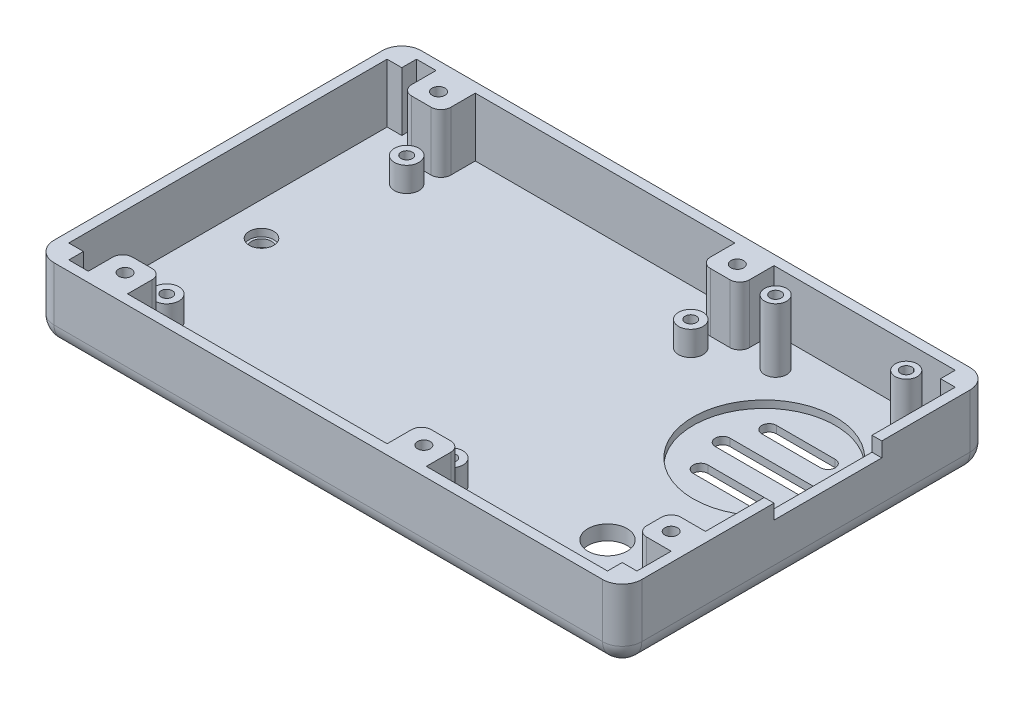
from build123d import *

# Parameters (mm, degrees)
SKETCH1_W                   = 120
SKETCH1_H                   = 75
MAIN_STRUCTURE_DEPTH        = 15
SKETCH2_W                   = 116
SKETCH2_H                   = 71
INSIDE_CUT_DEPTH            = 12
SKETCH3_R                   = 2.5
SKETCH3_R_2                 = 1.15
PI_STANDOFFS_DEPTH          = 5
SKETCH4_R                   = 2
SKETCH4_R_2                 = 0.9
CAMERA_STANDOFFS_DEPTH      = 5
BODY_FILLET_1_R             = 4
BODY_FILLET_2_R             = 4
BODY_FILLET_3_R             = 4
BODY_FILLET_4_R             = 4
SKETCH5_R                   = 2.25
SKETCH5_R_2                 = 1.15
FONA_STANDOFFS_DEPTH        = 13
SKETCH6_W                   = 3
SKETCH6_H                   = 3
CORNER_SUPPORT_DEPTH        = 12
SKETCH8_W                   = 22
SKETCH8_H                   = 3
CHARGER_CUTOUT_DEPTH        = 10
SKETCH9_W                   = 8
SKETCH9_H                   = 7
SKETCH9_W_2                 = 7
MOUNTING_STRUCTURE_DEPTH    = 12
MOUNTING_STRUCTURE_FILLET_R = 2
SKETCH10_R                  = 1.3
CASE_MOUNTING_HOLES_DEPTH   = 15
SKETCH13_R                  = 2.9
CASE_SCREW_HEAD_HOLES_DEPTH = 8.85
SKETCH14_R                  = 14.5
SPEAKER_HOLDER_DEPTH        = 1.5
SOUND_CUTOUT_DEPTH          = 1.5
SKETCH25_R                  = 2.5
MICROPHONE_HOLDER_DEPTH     = 1.5
SKETCH26_R                  = 2
MICROPHONE_CUTOUT_DEPTH     = 1.5
SKETCH27_R                  = 4
CAMERA_CUTOUT_DEPTH         = 10


with BuildPart() as part:
    # Sketch1 → Main Structure (new body)
    with BuildSketch(Plane(origin=(0, 0, 0), x_dir=(1, 0, 0), z_dir=(0, 1, 0))):
        Rectangle(SKETCH1_W, SKETCH1_H)
    extrude(amount=MAIN_STRUCTURE_DEPTH)

    # Sketch2 → Inside Cut (cut)
    with BuildSketch(Plane(origin=(0, 15, 0), x_dir=(1, 0, 0), z_dir=(0, 1, 0))):
        Rectangle(SKETCH2_W, SKETCH2_H)
    extrude(amount=-INSIDE_CUT_DEPTH, mode=Mode.SUBTRACT)

    # Sketch3 → Pi Standoffs (add)
    with BuildSketch(Plane(origin=(0, 3, 0), x_dir=(1, 0, 0), z_dir=(0, 1, 0))):
        with Locations((-46, -24.5)):
            Circle(SKETCH3_R)
        with Locations((-46, -24.5)):
            Circle(SKETCH3_R_2, mode=Mode.SUBTRACT)
        with Locations((-46, 24.5)):
            Circle(SKETCH3_R)
        with Locations((-46, 24.5)):
            Circle(SKETCH3_R_2, mode=Mode.SUBTRACT)
        with Locations((12, 24.5)):
            Circle(SKETCH3_R)
        with Locations((12, 24.5)):
            Circle(SKETCH3_R_2, mode=Mode.SUBTRACT)
        with Locations((12, -24.5)):
            Circle(SKETCH3_R)
        with Locations((12, -24.5)):
            Circle(SKETCH3_R_2, mode=Mode.SUBTRACT)
    extrude(amount=PI_STANDOFFS_DEPTH)

    # Sketch4 → Camera Standoffs (add)
    with BuildSketch(Plane(origin=(0, 3, 0), x_dir=(1, 0, 0), z_dir=(0, 1, 0))):
        with Locations((48, -30.5)):
            Circle(SKETCH4_R)
        with Locations((48, -30.5)):
            Circle(SKETCH4_R_2, mode=Mode.SUBTRACT)
        with Locations((48, -17.5)):
            Circle(SKETCH4_R)
        with Locations((48, -17.5)):
            Circle(SKETCH4_R_2, mode=Mode.SUBTRACT)
    extrude(amount=CAMERA_STANDOFFS_DEPTH)

    # Body Fillet 1
    body_fillet_1_edges = [part.edges().sort_by_distance(p)[0] for p in [
        (-60, 0, 0),
    ]]
    fillet(body_fillet_1_edges, radius=BODY_FILLET_1_R)

    # Body Fillet 2
    body_fillet_2_edges = [part.edges().sort_by_distance(p)[0] for p in [
        (2, 0, -37.5),
        (-58.828427125, 1.171572875, -37.5),
        (-60, 9.5, -37.5),
    ]]
    fillet(body_fillet_2_edges, radius=BODY_FILLET_2_R)

    # Body Fillet 3
    body_fillet_3_edges = [part.edges().sort_by_distance(p)[0] for p in [
        (2, 0, 37.5),
        (-58.828427125, 1.171572875, 37.5),
        (-60, 9.5, 37.5),
    ]]
    fillet(body_fillet_3_edges, radius=BODY_FILLET_3_R)

    # Body Fillet 4
    body_fillet_4_edges = [part.edges().sort_by_distance(p)[0] for p in [
        (60, 9.5, 37.5),
        (60, 9.5, -37.5),
        (60, 1.171572875, -36.328427125),
        (60, 0, 0),
        (60, 1.171572875, 36.328427125),
    ]]
    fillet(body_fillet_4_edges, radius=BODY_FILLET_4_R)

    # Sketch5 → Fona Standoffs (add)
    with BuildSketch(Plane(origin=(0, 3, 0), x_dir=(1, 0, 0), z_dir=(0, 1, 0))):
        with Locations((24.33, 29.5)):
            Circle(SKETCH5_R)
        with Locations((24.33, 29.5)):
            Circle(SKETCH5_R_2, mode=Mode.SUBTRACT)
        with Locations((51, 29.5)):
            Circle(SKETCH5_R)
        with Locations((51, 29.5)):
            Circle(SKETCH5_R_2, mode=Mode.SUBTRACT)
    extrude(amount=FONA_STANDOFFS_DEPTH)

    # Sketch6 → Corner Support (add)
    with BuildSketch(Plane(origin=(0, 3, 0), x_dir=(1, 0, 0), z_dir=(0, 1, 0))):
        with Locations((-56.5, -34)):
            Rectangle(SKETCH6_W, SKETCH6_H)
        with Locations((-56.5, 34)):
            Rectangle(SKETCH6_W, SKETCH6_H)
        with Locations((56.5, -34)):
            Rectangle(SKETCH6_W, SKETCH6_H)
        with Locations((56.5, 34)):
            Rectangle(SKETCH6_W, SKETCH6_H)
    extrude(amount=CORNER_SUPPORT_DEPTH)

    # Sketch8 → Charger Cutout (cut)
    with BuildSketch(Plane(origin=(60, 0, 0), x_dir=(0, 0, -1), z_dir=(1, 0, 0))):
        with Locations((4.5, 13.5)):
            Rectangle(SKETCH8_W, SKETCH8_H)
    extrude(amount=-CHARGER_CUTOUT_DEPTH, mode=Mode.SUBTRACT)

    # Sketch9 → Mounting Structure (add)
    with BuildSketch(Plane(origin=(0, 3, 0), x_dir=(1, 0, 0), z_dir=(0, 1, 0))):
        with Locations((-47, -32)):
            Rectangle(SKETCH9_W, SKETCH9_H)
        with Locations((54.5, -22)):
            Rectangle(SKETCH9_W_2, SKETCH9_H)
        with Locations((-47, 32)):
            Rectangle(SKETCH9_W, SKETCH9_H)
        with Locations((14, 32)):
            Rectangle(SKETCH9_W, SKETCH9_H)
        with Locations((14, -32)):
            Rectangle(SKETCH9_W, SKETCH9_H)
    extrude(amount=MOUNTING_STRUCTURE_DEPTH)

    # Mounting Structure Fillet
    mounting_structure_fillet_edges = [part.edges().sort_by_distance(p)[0] for p in [
        (-43, 9, 28.5),
        (-51, 9, 28.5),
        (51, 9, 18.5),
        (51, 9, 25.5),
        (-43, 9, -28.5),
        (-51, 9, -28.5),
        (18, 9, -28.5),
        (10, 9, -28.5),
        (18, 9, 28.5),
        (10, 9, 28.5),
    ]]
    fillet(mounting_structure_fillet_edges, radius=MOUNTING_STRUCTURE_FILLET_R)

    # Sketch10 → Case Mounting Holes (cut)
    with BuildSketch(Plane(origin=(0, 15, 0), x_dir=(1, 0, 0), z_dir=(0, 1, 0))):
        with Locations((-47, 32)):
            Circle(SKETCH10_R)
        with Locations((-47, -32)):
            Circle(SKETCH10_R)
        with Locations((14, -32)):
            Circle(SKETCH10_R)
        with Locations((14, 32)):
            Circle(SKETCH10_R)
        with Locations((54.5, -22)):
            Circle(SKETCH10_R)
    extrude(amount=-CASE_MOUNTING_HOLES_DEPTH, mode=Mode.SUBTRACT)

    # Sketch13 → Case Screw Head Holes (cut)
    with BuildSketch(Plane.XZ):
        with Locations((-47, 32)):
            Circle(SKETCH13_R)
        with Locations((14, 32)):
            Circle(SKETCH13_R)
        with Locations((14, -32)):
            Circle(SKETCH13_R)
        with Locations((-47, -32)):
            Circle(SKETCH13_R)
        with Locations((54.5, 22)):
            Circle(SKETCH13_R)
    extrude(amount=-CASE_SCREW_HEAD_HOLES_DEPTH, mode=Mode.SUBTRACT)

    # Sketch14 → Speaker Holder (cut)
    with BuildSketch(Plane(origin=(0, 3, 0), x_dir=(1, 0, 0), z_dir=(0, 1, 0))):
        with Locations((39, 12.5)):
            Circle(SKETCH14_R)
    extrude(amount=-SPEAKER_HOLDER_DEPTH, mode=Mode.SUBTRACT)

    # Sketch23 → Sound Cutout (cut)
    with BuildSketch(Plane(origin=(0, 1.5, 0), x_dir=(1, 0, 0), z_dir=(0, 1, 0))):
        with BuildLine():
            Line((33, 21), (45, 21))
            ThreePointArc((45, 21), (46.5, 19.5), (45, 18))
            Line((45, 18), (33, 18))
            ThreePointArc((33, 18), (31.5, 19.5), (33, 21))
        make_face()
        with BuildLine():
            Line((30.5, 14), (47.5, 14))
            ThreePointArc((47.5, 14), (49, 12.5), (47.5, 11))
            Line((47.5, 11), (30.5, 11))
            ThreePointArc((30.5, 11), (29, 12.5), (30.5, 14))
        make_face()
        with BuildLine():
            Line((33, 7), (45, 7))
            ThreePointArc((45, 7), (46.5, 5.5), (45, 4))
            Line((45, 4), (33, 4))
            ThreePointArc((33, 4), (31.5, 5.5), (33, 7))
        make_face()
    extrude(amount=-SOUND_CUTOUT_DEPTH, mode=Mode.SUBTRACT)

    # Sketch25 → Microphone holder (cut)
    with BuildSketch(Plane(origin=(0, 3, 0), x_dir=(1, 0, 0), z_dir=(0, 1, 0))):
        with Locations((-51.147743093, 0)):
            Circle(SKETCH25_R)
    extrude(amount=-MICROPHONE_HOLDER_DEPTH, mode=Mode.SUBTRACT)

    # Sketch26 → Microphone Cutout (cut)
    with BuildSketch(Plane(origin=(0, 1.5, 0), x_dir=(1, 0, 0), z_dir=(0, 1, 0))):
        with Locations((-51.147743093, 0)):
            Circle(SKETCH26_R)
    extrude(amount=-MICROPHONE_CUTOUT_DEPTH, mode=Mode.SUBTRACT)

    # Sketch27 → Camera Cutout (cut)
    with BuildSketch(Plane(origin=(0, 3, 0), x_dir=(1, 0, 0), z_dir=(0, 1, 0))):
        with Locations((37.5, -18)):
            Circle(SKETCH27_R)
    extrude(amount=-CAMERA_CUTOUT_DEPTH, mode=Mode.SUBTRACT)


solid = part.part
